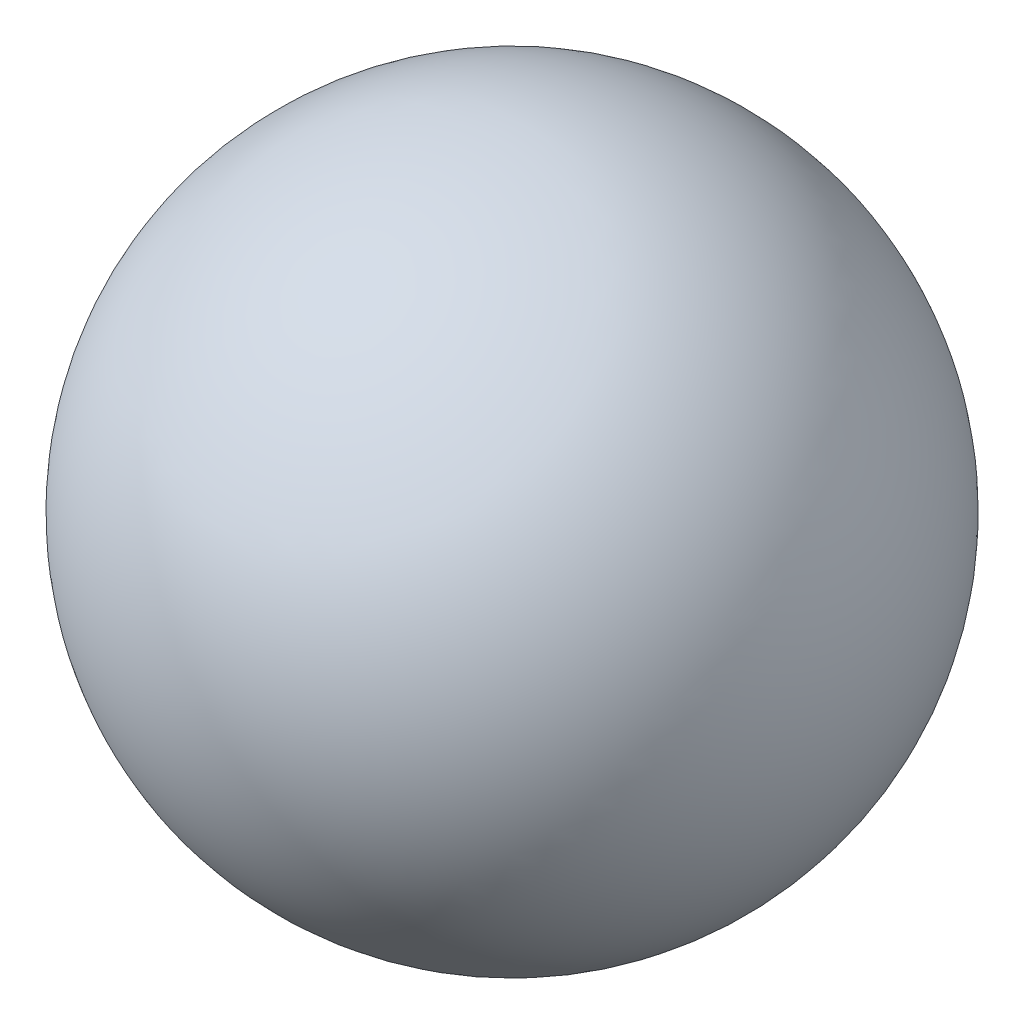
from build123d import *


with BuildPart() as part:
    # Sketch1 one side → Revolve1 (revolve)
    with BuildSketch(Plane(origin=(0, 0, 0), x_dir=(1, 0, 0), z_dir=(0, 1, 0))):
        with BuildLine():
            Line((81.04842189, -18.044791789), (81.04842189, 111.955208211))
            ThreePointArc((81.04842189, 111.955208211), (16.04842189, 46.955208211), (81.04842189, -18.044791789))
        make_face()
    revolve(axis=Axis((81.04842189, 0, 18.044791789), (0, 0, -1)))


solid = part.part
